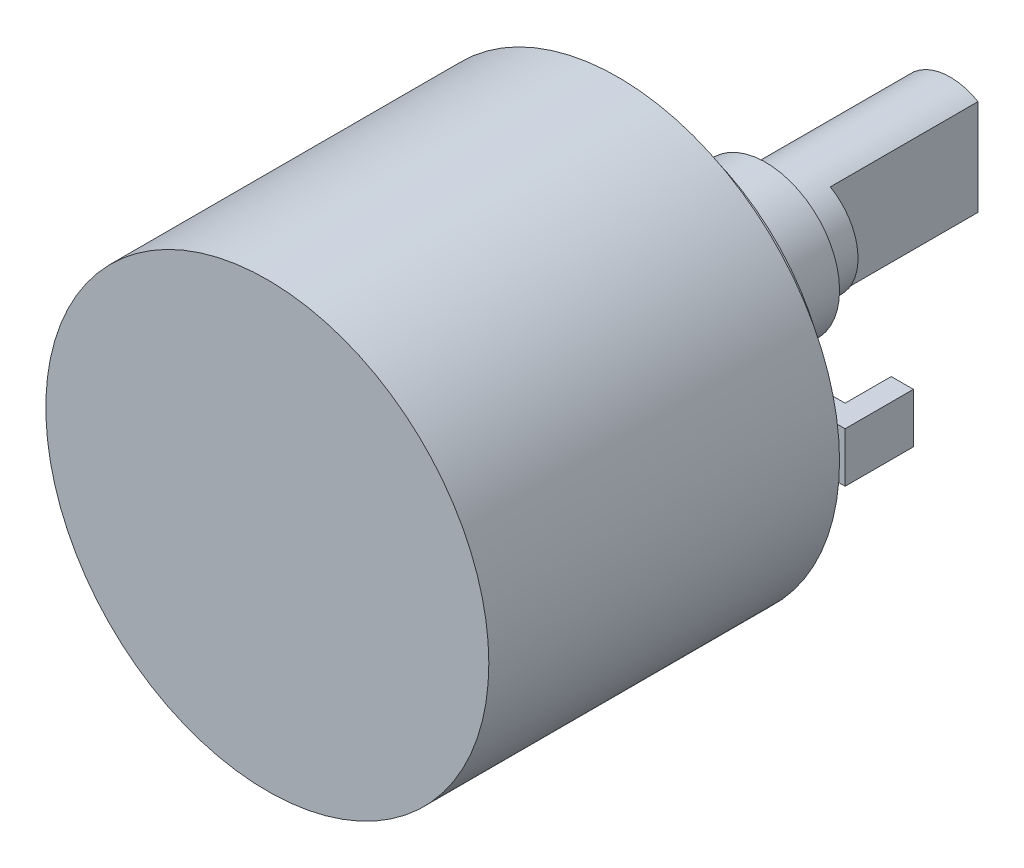
from build123d import *

# Parameters (mm, degrees)
SKETCH_2_W          = 1.2
SKETCH_2_H          = 2.7
EXTRUDE_1_DEPTH     = 2.5
SKETCH_3_W          = 12
SKETCH_3_H          = 2.7
EXTRUDE_2_DEPTH     = 1.2
CUT_EXTRUDE_1_DEPTH = 8


with BuildPart() as part:
    # Эскиз1 → Повернуть1 (revolve)
    with BuildSketch(Plane(origin=(0, 0, 0), x_dir=(0, 0, -1), z_dir=(1, 0, 0))):
        Polygon((-20.5, 0), (-20.5, 12), (-1.5, 12), (-1.5, 10), (0, 10), (0, 4), (6.5, 4), (6.5, 3), (16.5, 3), (16.5, 0), align=None)
    revolve(axis=Axis((0, 0, 20.5), (0, 0, -1)))



with BuildPart() as body_2:
    # Эскиз2 → Бобышка-Вытянуть1 (new body)
    with BuildSketch(Plane(origin=(0, 0, 0), x_dir=(-1, 0, 0), z_dir=(0, 0, -1))):
        with Locations((-11.4, 0)):
            Rectangle(SKETCH_2_W, SKETCH_2_H)
    extrude(amount=EXTRUDE_1_DEPTH)


with BuildPart() as part_1:
    add(part.part)

    add(body_2.part)  # Бобышка-Вытянуть2 merges body 2
    # Эскиз3 → Бобышка-Вытянуть2 (add)
    with BuildSketch(Plane.XY):
        with Locations((6, 0)):
            Rectangle(SKETCH_3_W, SKETCH_3_H)
    extrude(amount=EXTRUDE_2_DEPTH)

    # Эскиз4 → Вырез-Вытянуть1 (cut)
    with BuildSketch(Plane(origin=(0, 0, -16.5), x_dir=(-1, 0, 0), z_dir=(0, 0, -1))):
        with BuildLine():
            Line((-1.5, 2.598076211), (-1.5, -2.598076211))
            ThreePointArc((-1.5, -2.598076211), (-3, 0), (-1.5, 2.598076211))
        make_face()
    extrude(amount=-CUT_EXTRUDE_1_DEPTH, mode=Mode.SUBTRACT)


solid = part_1.part
